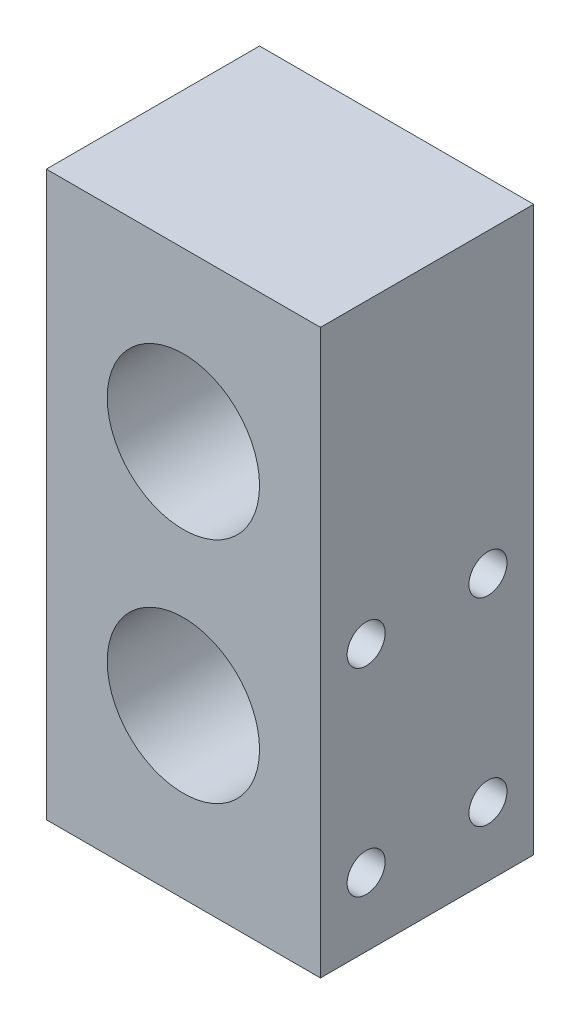
from build123d import *

# Parameters (mm, degrees)
SKETCH2_W                      = 18
SKETCH2_H                      = 14
BOSS_EXTRUDE1_DEPTH            = 37
SKETCH3_R                      = 5
CUT_EXTRUDE1_DEPTH             = 15
M3X0_5_TAPPED_HOLE1_AT_2_COUNT = 2
M3X0_5_TAPPED_HOLE1_AT_2_PITCH = 8
M3X0_5_TAPPED_HOLE1_AT_3_COUNT = 2
M3X0_5_TAPPED_HOLE1_AT_3_PITCH = 15.264337522
M3X0_5_TAPPED_HOLE1_AT_4_COUNT = 2
M3X0_5_TAPPED_HOLE1_AT_4_PITCH = 13


with BuildPart() as part:
    # Sketch2 → Boss-Extrude1 (new body)
    with BuildSketch(Plane(origin=(0, 0, 0), x_dir=(1, 0, 0), z_dir=(0, 1, 0))):
        Rectangle(SKETCH2_W, SKETCH2_H)
    extrude(amount=BOSS_EXTRUDE1_DEPTH)

    # Sketch3 → Cut-Extrude1 (cut, through all)
    with BuildSketch(Plane.XY.offset(7)):
        with Locations((0, 26)):
            Circle(SKETCH3_R)
        with Locations((0, 11)):
            Circle(SKETCH3_R)
    extrude(amount=-CUT_EXTRUDE1_DEPTH, mode=Mode.SUBTRACT)

    # Sketch5 → M3x0.5 Tapped Hole1 (revolve, cut)
    with BuildSketch(Plane(origin=(-9, 17.5, -4), x_dir=(0, 0, 1), z_dir=(0, 1, 0))):
        Polygon((0, 0), (0, 6.251075774), (1.25, 5.5), (1.25, 0), align=None)
    m3x0_5_tapped_hole1 = revolve(axis=Axis((-15.35, 17.5, -4), (1, 0, 0)), mode=Mode.SUBTRACT)

    # M3x0.5 Tapped Hole1 at 2: M3x0.5 Tapped Hole1 ×2
    with Locations(*[(0, 0, i * M3X0_5_TAPPED_HOLE1_AT_2_PITCH) for i in range(1, M3X0_5_TAPPED_HOLE1_AT_2_COUNT)]):
        add(m3x0_5_tapped_hole1, mode=Mode.SUBTRACT)

    # M3x0.5 Tapped Hole1 at 3: M3x0.5 Tapped Hole1 ×2
    with Locations(*[Vector(0, -0.851658317, 0.524097426) * (i * M3X0_5_TAPPED_HOLE1_AT_3_PITCH) for i in range(1, M3X0_5_TAPPED_HOLE1_AT_3_COUNT)]):
        add(m3x0_5_tapped_hole1, mode=Mode.SUBTRACT)

    # M3x0.5 Tapped Hole1 at 4: M3x0.5 Tapped Hole1 ×2
    with Locations(*[(0, -i * M3X0_5_TAPPED_HOLE1_AT_4_PITCH, 0) for i in range(1, M3X0_5_TAPPED_HOLE1_AT_4_COUNT)]):
        add(m3x0_5_tapped_hole1, mode=Mode.SUBTRACT)

    # Mirror1: M3x0.5 Tapped Hole1 across plane
    add(m3x0_5_tapped_hole1.mirror(Plane(origin=(0, 0, 0), x_dir=(0, 0, 1), z_dir=(1, 0, 0))), mode=Mode.SUBTRACT)

    # Mirror1 copy 1 sketch → Mirror1 copy 1 (revolve, cut)
    with BuildSketch(Plane(origin=(9, 17.5, 4), x_dir=(0, 0, 1), z_dir=(0, 1, 0))):
        Polygon((0, 0), (0, -6.251075774), (1.25, -5.5), (1.25, 0), align=None)
    revolve(axis=Axis((15.35, 17.5, 4), (1, 0, 0)), mode=Mode.SUBTRACT)

    # Mirror1 copy 2 sketch → Mirror1 copy 2 (revolve, cut)
    with BuildSketch(Plane(origin=(9, 4.5, 4), x_dir=(0, 0, 1), z_dir=(0, 1, 0))):
        Polygon((0, 0), (0, -6.251075774), (1.25, -5.5), (1.25, 0), align=None)
    revolve(axis=Axis((15.35, 4.5, 4), (1, 0, 0)), mode=Mode.SUBTRACT)

    # Mirror1 copy 3 sketch → Mirror1 copy 3 (revolve, cut)
    with BuildSketch(Plane(origin=(9, 4.5, -4), x_dir=(0, 0, 1), z_dir=(0, 1, 0))):
        Polygon((0, 0), (0, -6.251075774), (1.25, -5.5), (1.25, 0), align=None)
    revolve(axis=Axis((15.35, 4.5, -4), (1, 0, 0)), mode=Mode.SUBTRACT)


solid = part.part
